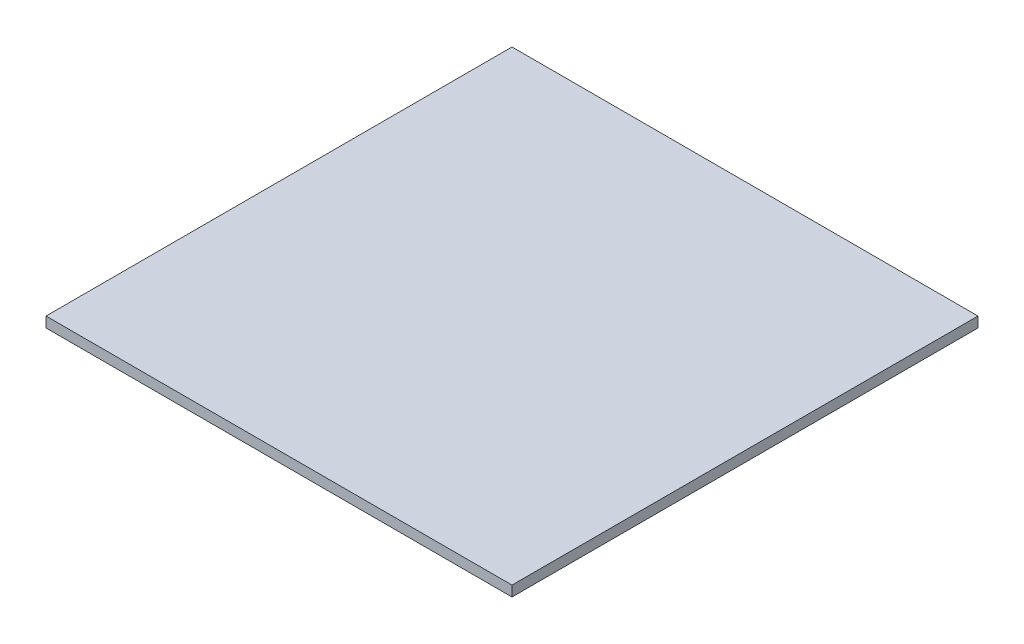
from build123d import *

# Parameters (mm, degrees)
SKETCH1_W           = 450
SKETCH1_H           = 450
BOSS_EXTRUDE1_DEPTH = 10


with BuildPart() as part:
    # Sketch1 → Boss-Extrude1 (new body)
    with BuildSketch(Plane(origin=(0, 0, 0), x_dir=(1, 0, 0), z_dir=(0, 1, 0))):
        Rectangle(SKETCH1_W, SKETCH1_H)
    extrude(amount=BOSS_EXTRUDE1_DEPTH)


solid = part.part
